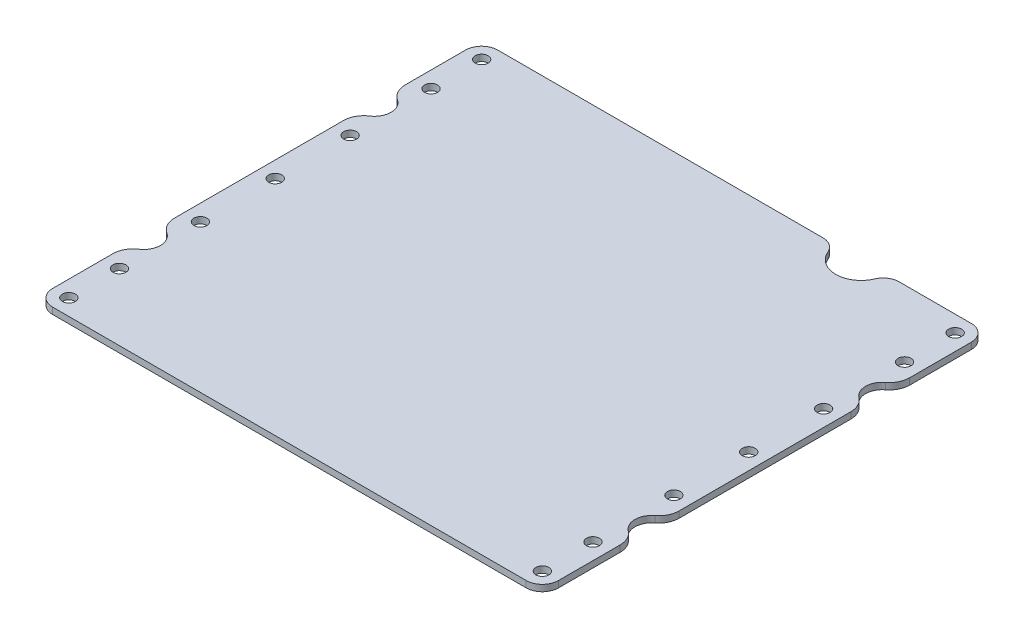
from build123d import *

# Parameters (mm, degrees)
SKETCH1_W           = 250
SKETCH1_H           = 220
BOSS_EXTRUDE1_DEPTH = 3.175
SKETCH2_R           = 3.2
CUT_EXTRUDE1_DEPTH  = 4.175
FILLET1_R           = 8
CUT_EXTRUDE3_DEPTH  = 4.175
FILLET3_R           = 8
SKETCH5_R           = 8.25
CUT_EXTRUDE4_DEPTH  = 4.175
FILLET4_R           = 10
FILLET5_R           = 8
BOSS_EXTRUDE2_DEPTH = 3.175
FILLET6_R           = 10
SKETCH7_R           = 3.2
CUT_EXTRUDE5_DEPTH  = 4.175


with BuildPart() as part:
    # Sketch1 → Boss-Extrude1 (new body)
    with BuildSketch(Plane(origin=(0, 0, 0), x_dir=(1, 0, 0), z_dir=(0, 1, 0))):
        Rectangle(SKETCH1_W, SKETCH1_H)
    extrude(amount=BOSS_EXTRUDE1_DEPTH)

    # Sketch2 → Cut-Extrude1 (cut, through all)
    with BuildSketch(Plane(origin=(0, 3.175, 0), x_dir=(-1, 0, 0), z_dir=(0, 1, 0))):
        with Locations((117, -102)):
            Circle(SKETCH2_R)
        with Locations((-117, -102)):
            Circle(SKETCH2_R)
        with Locations((-117, 102)):
            Circle(SKETCH2_R)
        with Locations((117, 102)):
            Circle(SKETCH2_R)
        with Locations((117, -77)):
            Circle(SKETCH2_R)
        with Locations((117, 77)):
            Circle(SKETCH2_R)
        with Locations((-117, 77)):
            Circle(SKETCH2_R)
        with Locations((-117, -77)):
            Circle(SKETCH2_R)
        with Locations((117, 37)):
            Circle(SKETCH2_R)
        with Locations((117, -37)):
            Circle(SKETCH2_R)
        with Locations((-117, -37)):
            Circle(SKETCH2_R)
        with Locations((-117, 37)):
            Circle(SKETCH2_R)
    extrude(amount=-CUT_EXTRUDE1_DEPTH, mode=Mode.SUBTRACT)

    # Fillet1
    fillet1_edges = [part.edges().sort_by_distance(p)[0] for p in [
        (-125, 1.5875, -110),
        (125, 1.5875, -110),
        (125, 1.5875, 110),
        (-125, 1.5875, 110),
    ]]
    fillet(fillet1_edges, radius=FILLET1_R)

    # Sketch4 → Cut-Extrude3 (cut, through all)
    with BuildSketch(Plane(origin=(0, 3.175, 0), x_dir=(1, 0, 0), z_dir=(0, 1, 0))):
        with BuildLine():
            Line((75, 110), (50, 110))
            ThreePointArc((50, 110), (62.5, 97.5), (75, 110))
        make_face()
    extrude(amount=-CUT_EXTRUDE3_DEPTH, mode=Mode.SUBTRACT)

    # Fillet3
    fillet3_edges = [part.edges().sort_by_distance(p)[0] for p in [
        (75, 1.5875, -110),
        (50, 1.5875, -110),
    ]]
    fillet(fillet3_edges, radius=FILLET3_R)

    # Sketch5 → Cut-Extrude4 (cut, through all)
    with BuildSketch(Plane(origin=(0, 3.175, 0), x_dir=(1, 0, 0), z_dir=(0, 1, 0))):
        with Locations((-125, 57)):
            Circle(SKETCH5_R)
        with Locations((-125, -57)):
            Circle(SKETCH5_R)
        with BuildLine():
            Line((108.641149162, 70.240746381), (117.711258049, 53.135192013))
            ThreePointArc((117.711258049, 53.135192013), (132.069199597, 52.746893247), (125, 65.25))
            Line((125, 65.25), (125, 77.296464556))
            ThreePointArc((125, 77.296464556), (120.427492424, 70.453223368), (112.355339059, 72.058874503))
            Line((112.355339059, 72.058874503), (111.82233047, 72.591883092))
            ThreePointArc((111.82233047, 72.591883092), (109.219390768, 72.786063189), (108.641149162, 70.240746381))
        make_face()
        with BuildLine():
            Line((112.355339059, -72.058874503), (111.82233047, -72.591883092))
            ThreePointArc((111.82233047, -72.591883092), (109.219390768, -72.786063189), (108.641149162, -70.240746381))
            Line((108.641149162, -70.240746381), (117.711258049, -53.135192013))
            ThreePointArc((117.711258049, -53.135192013), (132.069199597, -52.746893247), (125, -65.25))
            Line((125, -65.25), (125, -77.296464556))
            ThreePointArc((125, -77.296464556), (120.427492424, -70.453223368), (112.355339059, -72.058874503))
        make_face()
    extrude(amount=-CUT_EXTRUDE4_DEPTH, mode=Mode.SUBTRACT)

    # Fillet4
    fillet4_edges = [part.edges().sort_by_distance(p)[0] for p in [
        (-125, 1.5875, -65.25),
        (-125, 1.5875, -48.75),
        (-125, 1.5875, 48.75),
        (-125, 1.5875, 65.25),
    ]]
    fillet(fillet4_edges, radius=FILLET4_R)

    # Fillet5
    fillet5_edges = [part.edges().sort_by_distance(p)[0] for p in [
        (125, 1.5875, -48.75),
        (125, 1.5875, 48.75),
    ]]
    fillet(fillet5_edges, radius=FILLET5_R)

    # Sketch6 → Boss-Extrude2 (add)
    with BuildSketch(Plane(origin=(0, 3.175, 0), x_dir=(1, 0, 0), z_dir=(0, 1, 0))):
        with BuildLine():
            Line((125, 65.189169677), (125, 77.296464556))
            Line((125, 77.296464556), (116.645162041, 73.27854658))
            Line((116.645162041, 73.27854658), (108.408116908, 79.390702383))
            Line((108.408116908, 79.390702383), (108.408116908, 56.119015219))
            Line((108.408116908, 56.119015219), (125, 42.85565484))
            Line((125, 42.85565484), (125, 48.810830323))
            ThreePointArc((125, 48.810830323), (117.75, 57), (125, 65.189169677))
        make_face()
        with BuildLine():
            Line((125, -42.85565484), (125, -48.810830323))
            ThreePointArc((125, -48.810830323), (117.75, -57), (125, -65.189169677))
            Line((125, -65.189169677), (125, -77.296464556))
            Line((125, -77.296464556), (116.645162041, -73.27854658))
            Line((116.645162041, -73.27854658), (108.408116908, -79.390702383))
            Line((108.408116908, -79.390702383), (108.408116908, -56.119015219))
            Line((108.408116908, -56.119015219), (125, -42.85565484))
        make_face()
    extrude(amount=-BOSS_EXTRUDE2_DEPTH)

    # Fillet6
    fillet6_edges = [part.edges().sort_by_distance(p)[0] for p in [
        (125, 1.5875, -65.189169677),
        (125, 1.5875, -48.810830323),
        (125, 1.5875, 48.810830323),
        (125, 1.5875, 65.189169677),
    ]]
    fillet(fillet6_edges, radius=FILLET6_R)

    # Sketch7 → Cut-Extrude5 (cut, through all)
    with BuildSketch(Plane(origin=(0, 3.175, 0), x_dir=(1, 0, 0), z_dir=(0, 1, 0))):
        with Locations((117.002495653, 0)):
            Circle(SKETCH7_R)
        with Locations((-117.002495653, 0)):
            Circle(SKETCH7_R)
    extrude(amount=-CUT_EXTRUDE5_DEPTH, mode=Mode.SUBTRACT)


solid = part.part
